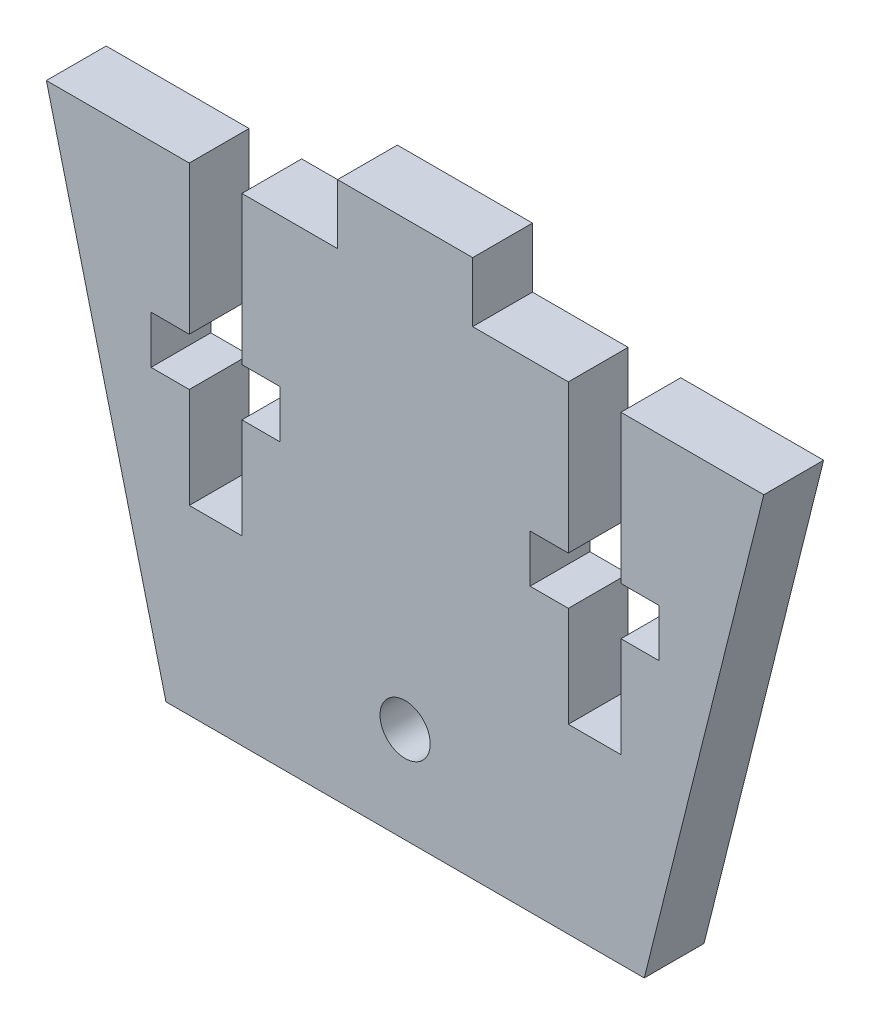
from build123d import *

# Parameters (mm, degrees)
SKETCH1_W           = 3.58775
SKETCH1_H           = 3.175
BOSS_EXTRUDE1_DEPTH = 3.175


with BuildPart() as part:
    # Sketch1 → Boss-Extrude1 (new body)
    with BuildSketch(Plane.XY):
        with BuildLine():
            Line((0, 3.7465), (0, 0))
            Line((0, 0), (12.7, 0))
            Line((12.7, 0), (19.05, 25.4))
            Line((19.05, 25.4), (11.46175, 25.4))
            Line((11.46175, 25.4), (11.46175, 17.526))
            Line((11.46175, 17.526), (13.49375, 17.526))
            Line((13.49375, 17.526), (13.49375, 14.986))
            Line((13.49375, 14.986), (11.46175, 14.986))
            Line((11.46175, 14.986), (11.46175, 9.652))
            Line((11.46175, 9.652), (8.66775, 9.652))
            Line((8.66775, 9.652), (8.66775, 14.986))
            Line((8.66775, 14.986), (6.63575, 14.986))
            Line((6.63575, 14.986), (6.63575, 17.526))
            Line((6.63575, 17.526), (8.66775, 17.526))
            Line((8.66775, 17.526), (8.66775, 25.4))
            Line((8.66775, 25.4), (3.58775, 25.4))
            Line((3.58775, 25.4), (0, 25.4))
            Line((0, 25.4), (0, 6.4135))
            ThreePointArc((0, 6.4135), (0.942926893, 6.022926893), (1.3335, 5.08))
            ThreePointArc((1.3335, 5.08), (0.942926893, 4.137073107), (0, 3.7465))
        make_face()
        with BuildLine():
            Line((-12.7, 0), (0, 0))
            Line((0, 0), (0, 3.7465))
            ThreePointArc((0, 3.7465), (-1.3335, 5.08), (0, 6.4135))
            Line((0, 6.4135), (0, 25.4))
            Line((0, 25.4), (-3.58775, 25.4))
            Line((-3.58775, 25.4), (-8.66775, 25.4))
            Line((-8.66775, 25.4), (-8.66775, 17.526))
            Line((-8.66775, 17.526), (-6.63575, 17.526))
            Line((-6.63575, 17.526), (-6.63575, 14.986))
            Line((-6.63575, 14.986), (-8.66775, 14.986))
            Line((-8.66775, 14.986), (-8.66775, 9.652))
            Line((-8.66775, 9.652), (-10.06475, 9.652))
            Line((-10.06475, 9.652), (-11.46175, 9.652))
            Line((-11.46175, 9.652), (-11.46175, 14.986))
            Line((-11.46175, 14.986), (-13.49375, 14.986))
            Line((-13.49375, 14.986), (-13.49375, 17.526))
            Line((-13.49375, 17.526), (-11.46175, 17.526))
            Line((-11.46175, 17.526), (-11.46175, 25.4))
            Line((-11.46175, 25.4), (-19.05, 25.4))
            Line((-19.05, 25.4), (-12.7, 0))
        make_face()
        with Locations((1.793875, 26.9875)):
            Rectangle(SKETCH1_W, SKETCH1_H)
        with Locations((-1.793875, 26.9875)):
            Rectangle(SKETCH1_W, SKETCH1_H)
    extrude(amount=BOSS_EXTRUDE1_DEPTH)


solid = part.part
